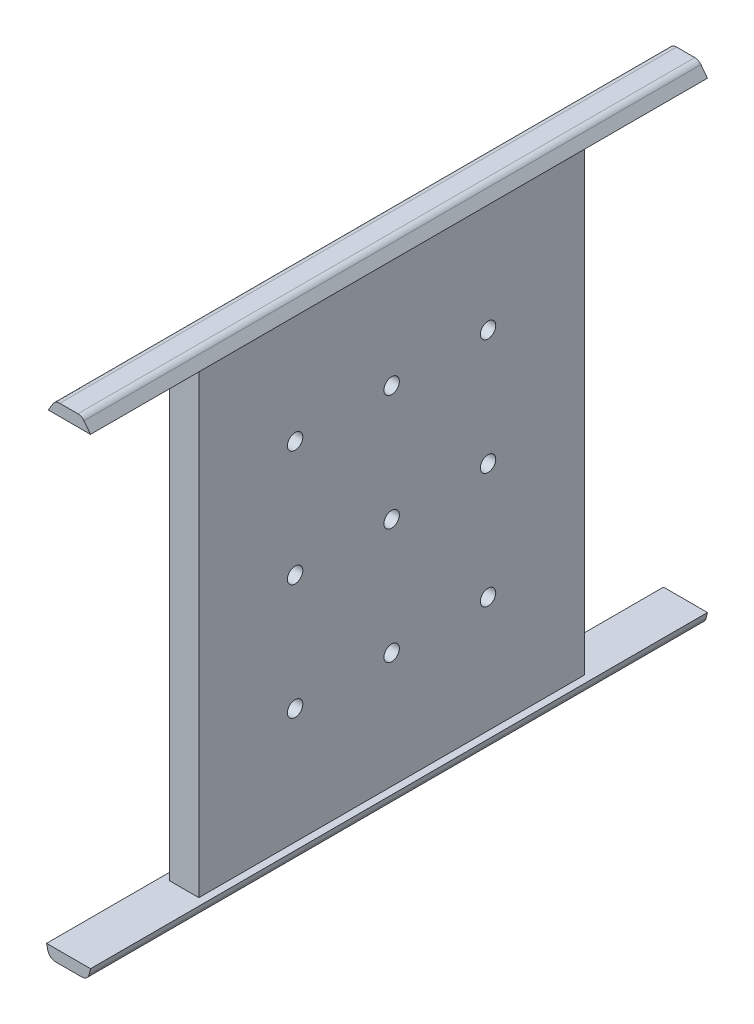
from build123d import *

# Parameters (mm, degrees)
RESSALTO_EXTRUS_O1_DEPTH = 160
ESBO_O2_W                = 7.6
ESBO_O2_H                = 120
CORTE_EXTRUS_O1_DEPTH    = 30
CORTE_EXTRUS_O2_DEPTH    = 30
F_3DSKETCH3_R            = 2
CORTE_EXTRUS_O3_DEPTH    = 70


with BuildPart() as part:
    # Esboço1 → Ressalto-extrusão1 (new body)
    with BuildSketch(Plane.XY):
        with BuildLine():
            Line((-3.8, 21.821375341), (-3.8, -98.178624659))
            Line((-3.8, -98.178624659), (-5.7, -98.178624659))
            Line((-5.7, -98.178624659), (-5.360626179, -99.63308389))
            ThreePointArc((-5.360626179, -99.63308389), (-4.656141559, -100.745296045), (-3.41294376, -101.178624659))
            Line((-3.41294376, -101.178624659), (3.41294376, -101.178624659))
            ThreePointArc((3.41294376, -101.178624659), (4.656141559, -100.745296045), (5.360626179, -99.63308389))
            Line((5.360626179, -99.63308389), (5.7, -98.178624659))
            Line((5.7, -98.178624659), (3.8, -98.178624659))
            Line((3.8, -98.178624659), (3.8, 21.821375341))
            Line((3.8, 21.821375341), (5.7, 21.821375341))
            Line((5.7, 21.821375341), (4.013268169, 24.033911877))
            ThreePointArc((4.013268169, 24.033911877), (3.310139149, 24.613730366), (2.422747768, 24.821375341))
            Line((2.422747768, 24.821375341), (-2.297792791, 24.821375341))
            ThreePointArc((-2.297792791, 24.821375341), (-3.27177376, 24.568189891), (-3.999156919, 23.872736414))
            Line((-3.999156919, 23.872736414), (-5.266799243, 21.821375341))
            Line((-5.266799243, 21.821375341), (-3.8, 21.821375341))
        make_face()
    extrude(amount=RESSALTO_EXTRUS_O1_DEPTH)

    # Esboço2 → Corte-extrusão1 (cut)
    with BuildSketch(Plane.XY):
        with Locations((0, -38.178624659)):
            Rectangle(ESBO_O2_W, ESBO_O2_H)
    extrude(amount=CORTE_EXTRUS_O1_DEPTH, mode=Mode.SUBTRACT)

    # 3DSketch2 → Corte-extrusão2 (cut)
    with BuildSketch(Plane(origin=(-3.8, 21.821375341, 160), x_dir=(0.0632066956560733, -0.9980004577274705, 0), z_dir=(0, 0, -1))):
        Polygon((0, 0), (0.480370887, -7.584803479), (120.240425814, 0), (119.760054927, 7.584803479), align=None)
    extrude(amount=CORTE_EXTRUS_O2_DEPTH, mode=Mode.SUBTRACT)

    # 3DSketch3 → Corte-extrusão3 (cut)
    with BuildSketch(Plane(origin=(3.8, -38.178624659, 80), x_dir=(0, 0.7676852805184269, 0.6408270516101394), z_dir=(1, 0, 0))):
        with Locations(Location((0, 0, 0), (0, 0, 140.146481665))):
            Circle(F_3DSKETCH3_R)
        with Locations(Location((23.030558416, -19.224811548, 0), (0, 0, 140.146481665))):
            Circle(F_3DSKETCH3_R)
        with Locations(Location((-23.030558416, 19.224811548, 0), (0, 0, 140.146481665))):
            Circle(F_3DSKETCH3_R)
        with Locations(Location((-39.051234706, 0.032679535, 0), (0, 0, 140.146481665))):
            Circle(F_3DSKETCH3_R)
        with Locations(Location((-16.02067629, -19.192132013, 0), (0, 0, 140.146481665))):
            Circle(F_3DSKETCH3_R)
        with Locations(Location((7.009882125, -38.416943561, 0), (0, 0, 140.146481665))):
            Circle(F_3DSKETCH3_R)
        with Locations(Location((-6.982602808, 38.449623097, 0), (0, 0, 140.146481665))):
            Circle(F_3DSKETCH3_R)
        with Locations(Location((16.047955607, 19.224811548, 0), (0, 0, 140.146481665))):
            Circle(F_3DSKETCH3_R)
        with Locations(Location((39.078514023, 0, 0), (0, 0, 140.146481665))):
            Circle(F_3DSKETCH3_R)
    extrude(amount=-CORTE_EXTRUS_O3_DEPTH, mode=Mode.SUBTRACT)


solid = part.part
